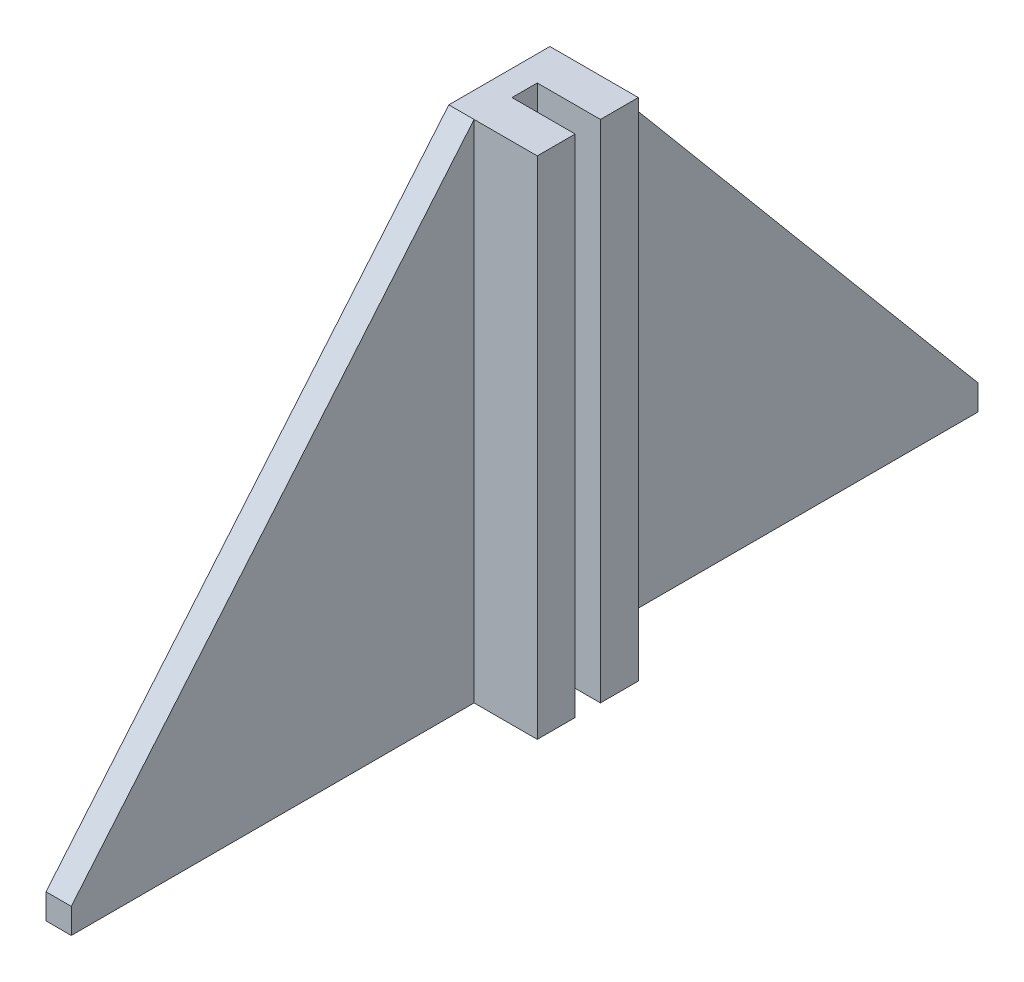
from build123d import *

# Parameters (mm, degrees)
BOSS_EXTRUDE1_DEPTH = 20
SKETCH3_W           = 30
SKETCH3_H           = 400
BOSS_EXTRUDE2_DEPTH = 50


with BuildPart() as part:
    # Sketch2 → Boss-Extrude1 (new body)
    with BuildSketch(Plane(origin=(0, 0, 0), x_dir=(0, 0, -1), z_dir=(1, 0, 0))):
        Polygon((-40, 400), (40, 400), (358.857859847, 20), (358.857859847, 0), (-358.857859847, 0), (-358.857859847, 20), align=None)
    extrude(amount=BOSS_EXTRUDE1_DEPTH)

    # Sketch3 → Boss-Extrude2 (add)
    with BuildSketch(Plane(origin=(20, 0, 0), x_dir=(0, 0, -1), z_dir=(1, 0, 0))):
        with Locations((-25, 200)):
            Rectangle(SKETCH3_W, SKETCH3_H)
        with Locations((25, 200)):
            Rectangle(SKETCH3_W, SKETCH3_H)
    extrude(amount=BOSS_EXTRUDE2_DEPTH)


solid = part.part
